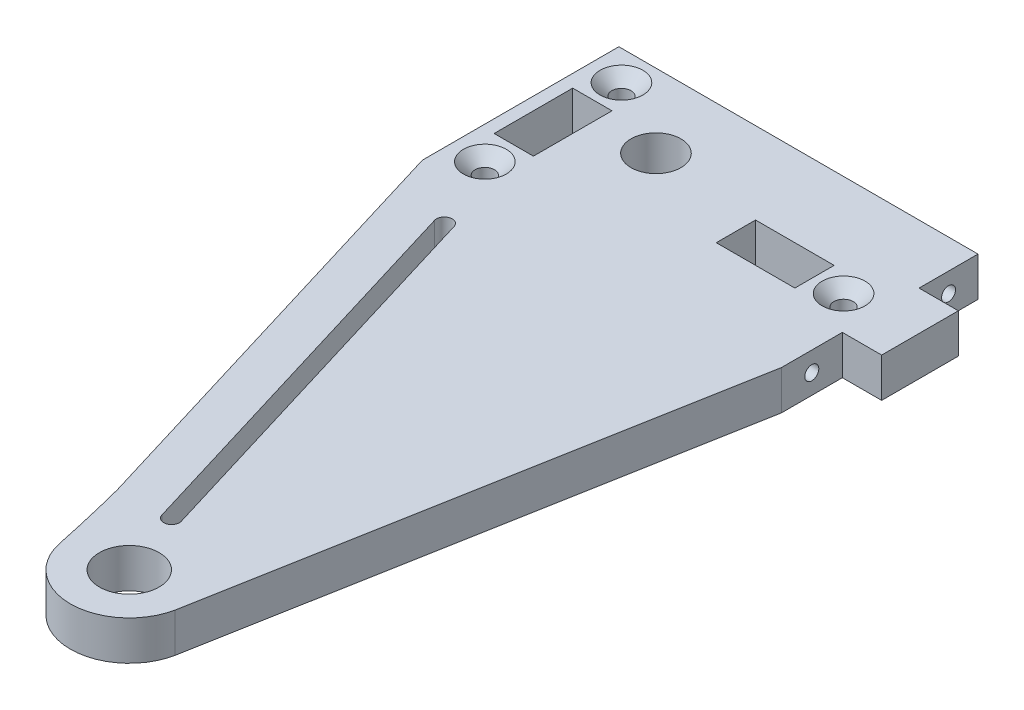
from build123d import *

# Parameters (mm, degrees)
SKETCH1_R           = 4.826
SKETCH1_R_2         = 1.5621
SKETCH1_R_3         = 4.0386
SKETCH1_W           = 12.7
SKETCH1_H           = 6.35
SKETCH1_W_2         = 6.35
SKETCH1_H_2         = 12.7
BOSS_EXTRUDE1_DEPTH = 6.35
SKETCH2_R           = 1.1303
CUT_EXTRUDE1_DEPTH  = 12.7
CHAMFER1_SIZE       = 1.905


with BuildPart() as part:
    # Sketch1 → Boss-Extrude1 (new body)
    with BuildSketch(Plane(origin=(0, 0, 0), x_dir=(1, 0, 0), z_dir=(0, 1, 0))):
        with BuildLine():
            Line((24.384, 81.026), (9.322766338, -1.952345462))
            ThreePointArc((9.322766338, -1.952345462), (0, -9.525), (-9.322766338, -1.952345462))
            ThreePointArc((-9.322766338, -1.952345462), (-10.68238726, 4.182597127), (-12.184698283, 10.284166696))
            Line((-12.184698283, 10.284166696), (-33.655, 81.026))
            Line((-33.655, 81.026), (-33.655, 112.776))
            Line((-33.655, 112.776), (-30.48, 112.776))
            Line((-30.48, 112.776), (24.384, 112.776))
            Line((24.384, 112.776), (24.384, 103.251))
            Line((24.384, 103.251), (30.734, 103.251))
            Line((30.734, 103.251), (30.734, 90.8558))
            Line((30.734, 90.8558), (24.384, 90.8558))
            Line((24.384, 90.8558), (24.384, 81.026))
        make_face()
        Circle(SKETCH1_R, mode=Mode.SUBTRACT)
        with Locations((-28.415132449, 107.954943271)):
            Circle(SKETCH1_R_2, mode=Mode.SUBTRACT)
        with Locations((-28.394285298, 85.856962938)):
            Circle(SKETCH1_R_2, mode=Mode.SUBTRACT)
        with Locations((-15.748, 100.8634)):
            Circle(SKETCH1_R_3, mode=Mode.SUBTRACT)
        with Locations((19.043196245, 96.393)):
            Circle(SKETCH1_R_2, mode=Mode.SUBTRACT)
        with BuildLine():
            Line((-5.032922832, 10.284166696), (-24.24305587, 73.5790401))
            ThreePointArc((-24.24305587, 73.5790401), (-23.396628753, 75.163136415), (-21.812532438, 74.316709298))
            Line((-21.812532438, 74.316709298), (-2.6023994, 11.021835893))
            ThreePointArc((-2.6023994, 11.021835893), (-3.448826517, 9.437739578), (-5.032922832, 10.284166696))
        make_face(mode=Mode.SUBTRACT)
        with Locations((7.994206079, 96.393)):
            Rectangle(SKETCH1_W, SKETCH1_H, mode=Mode.SUBTRACT)
        with Locations((-28.415132449, 96.901)):
            Rectangle(SKETCH1_W_2, SKETCH1_H_2, mode=Mode.SUBTRACT)
    extrude(amount=BOSS_EXTRUDE1_DEPTH)

    # Sketch2 → Cut-Extrude1 (cut)
    with BuildSketch(Plane(origin=(24.384, 0, 0), x_dir=(0, 0, -1), z_dir=(1, 0, 0))):
        with Locations((108.0135, 3.175)):
            Circle(SKETCH2_R)
        with Locations((85.9155, 3.175)):
            Circle(SKETCH2_R)
    extrude(amount=-CUT_EXTRUDE1_DEPTH, mode=Mode.SUBTRACT)

    # Chamfer1
    chamfer1_edges = [part.edges().sort_by_distance(p)[0] for p in [
        (17.481096245, 6.35, -96.393),
        (-29.977232449, 6.35, -107.954943271),
        (-29.956385298, 6.35, -85.856962938),
    ]]
    chamfer(chamfer1_edges, length=CHAMFER1_SIZE)


solid = part.part
